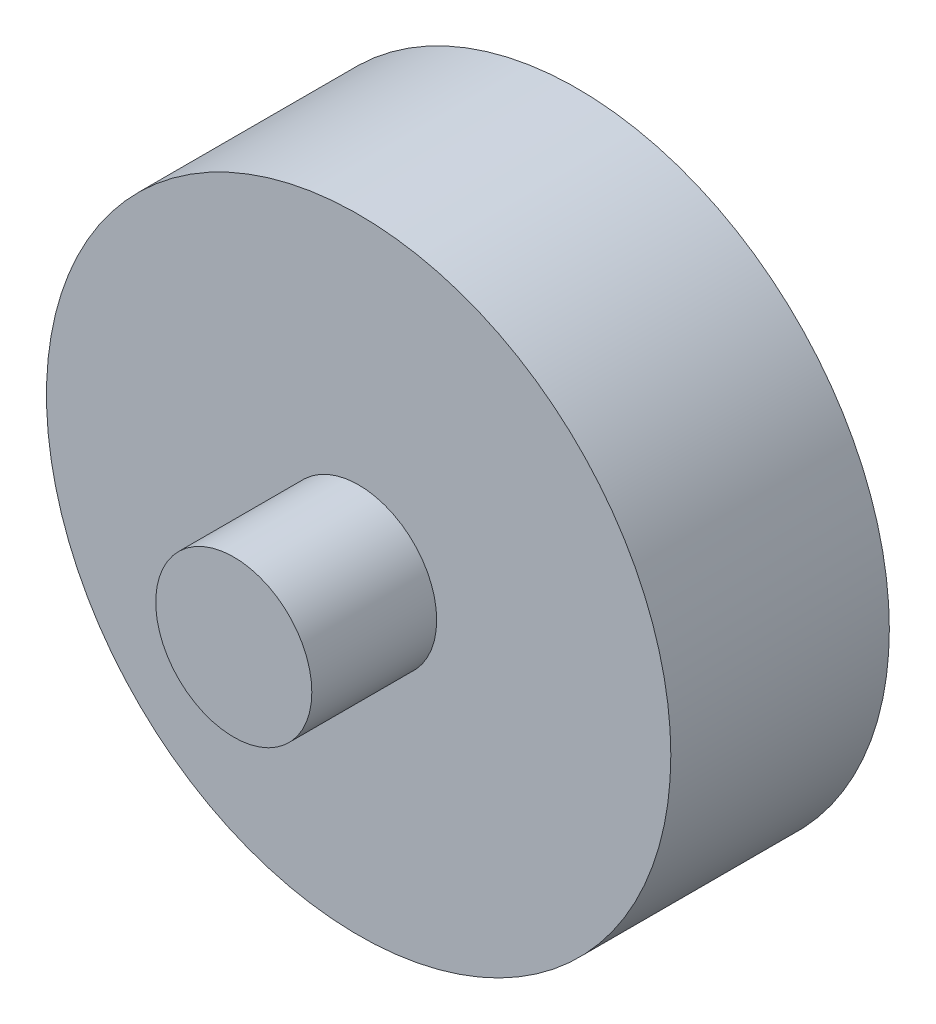
from build123d import *

# Parameters (mm, degrees)
SKETCH1_R           = 2.5
BOSS_EXTRUDE1_DEPTH = 11
SKETCH1_3_R         = 10
SKETCH1_3_R_2       = 2.5
BOSS_EXTRUDE2_DEPTH = 7


with BuildPart() as part:
    # Sketch1 → Boss-Extrude1 (new body)
    with BuildSketch(Plane.XY):
        with Locations((10, 10)):
            Circle(SKETCH1_R)
    extrude(amount=BOSS_EXTRUDE1_DEPTH)

    # Sketch1_3 → Boss-Extrude2 (add)
    with BuildSketch(Plane.XY):
        with Locations((10, 10)):
            Circle(SKETCH1_3_R)
        with Locations((10, 10)):
            Circle(SKETCH1_3_R_2, mode=Mode.SUBTRACT)
    extrude(amount=BOSS_EXTRUDE2_DEPTH)


solid = part.part
